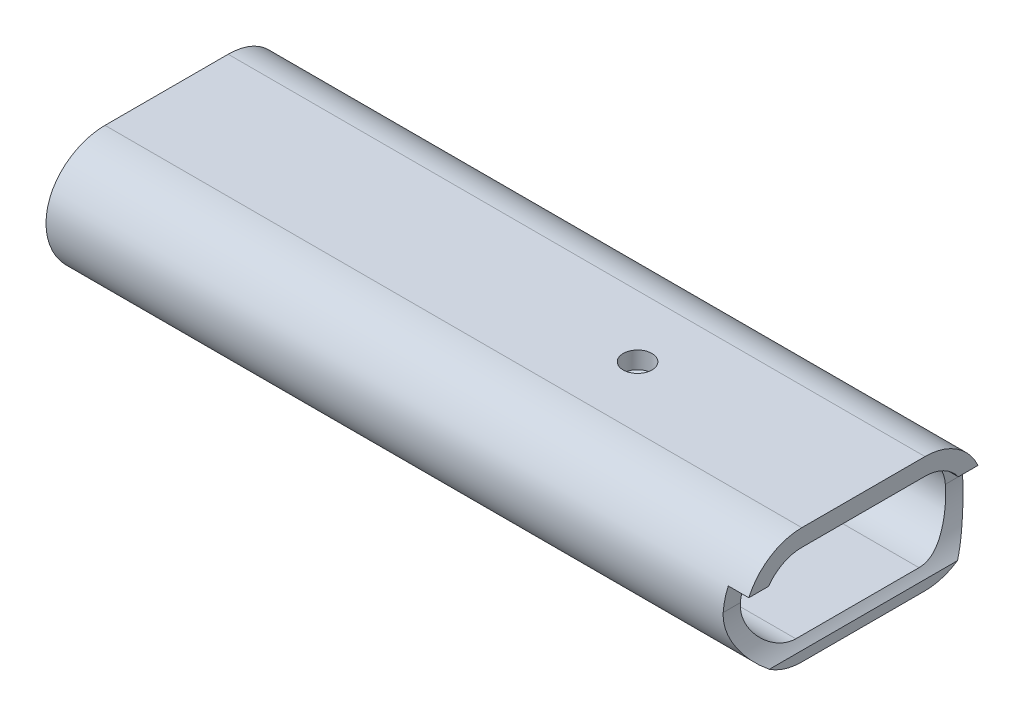
from build123d import *

# Parameters (mm, degrees)
EXTRUSION1_DEPTH             = 51
ENL_V_MAT_EXTRU_2_DEPTH      = 18.5
ENL_V_MAT_EXTRU_2_DEPTH_BACK = 18.5
ENL_V_MAT_EXTRU_3_REACH      = 19
ESQUISSE4_R                  = 2.1
ENL_V_MAT_EXTRU_4_DEPTH      = 18.5000001
ENL_V_MAT_EXTRU_4_DEPTH_BACK = 18.5000001


with BuildPart() as part:
    # Esquisse1 → Extrusion1 (new body, symmetric)
    with BuildSketch(Plane(origin=(0, 0, 0), x_dir=(0, 0, -1), z_dir=(1, 0, 0))):
        with BuildLine():
            Line((-9, -8.5), (9, -8.5))
            ThreePointArc((9, -8.5), (17.5, 0), (9, 8.5))
            Line((9, 8.5), (-9, 8.5))
            ThreePointArc((-9, 8.5), (-17.5, 0), (-9, -8.5))
        make_face()
        with BuildLine():
            Line((-9, 6), (9, 6))
            ThreePointArc((9, 6), (15, 0), (9, -6))
            Line((9, -6), (-9, -6))
            ThreePointArc((-9, -6), (-15, 0), (-9, 6))
        make_face(mode=Mode.SUBTRACT)
    extrude(amount=EXTRUSION1_DEPTH, both=True)

    # Esquisse3 → Enlèv. mat.-Extru.2 (cut, two sides)
    with BuildSketch(Plane.XY) as enl_v_mat_extru_2_sk:
        with BuildLine():
            Line((51, 3.5), (48, 3.5))
            Line((48, 3.5), (48, 0.5))
            ThreePointArc((48, 0.5), (48.77747585, -3.562019202), (51, -7.049834435))
            Line((51, -7.049834435), (51, 3.5))
        make_face()
    extrude(amount=ENL_V_MAT_EXTRU_2_DEPTH, mode=Mode.SUBTRACT)
    extrude(enl_v_mat_extru_2_sk.sketch, amount=-ENL_V_MAT_EXTRU_2_DEPTH_BACK, mode=Mode.SUBTRACT)

    # Esquisse4 → Enlèv. mat.-Extru.3 (cut, up to next)
    with BuildSketch(Plane(origin=(0, 8.5, 0), x_dir=(-1, 0, 0), z_dir=(0, 1, 0)), mode=Mode.PRIVATE) as enl_v_mat_extru_3_sk1:
        with Locations(Location((-18, 0, 0), (0, 0, 90))):  # turned: the seam where the file's is
            Circle(ESQUISSE4_R)
    enl_v_mat_extru_3_tool1 = extrude(enl_v_mat_extru_3_sk1.sketch, amount=-ENL_V_MAT_EXTRU_3_REACH, mode=Mode.PRIVATE) & part.part
    add(enl_v_mat_extru_3_tool1.solids().sort_by_distance((18, 8.5, 0))[0], mode=Mode.SUBTRACT)

    # Esquisse5 → Enlèv. mat.-Extru.4 (cut, two sides)
    with BuildSketch(Plane.XY) as enl_v_mat_extru_4_sk:
        with BuildLine():
            Line((60.682276478, -226.426742354), (-41.324705982, -35.5))
            ThreePointArc((-41.324705982, -35.5), (-49.153043001, -14.164640947), (-50.824705982, 8.5))
            Line((-50.824705982, 8.5), (-36.678065011, 224.505365595))
            Line((-36.678065011, 224.505365595), (-459.862900179, 133.135912547))
            Line((-459.862900179, 133.135912547), (-362.50255869, -317.796195402))
            Line((-362.50255869, -317.796195402), (60.682276478, -226.426742354))
        make_face()
    extrude(amount=ENL_V_MAT_EXTRU_4_DEPTH, mode=Mode.SUBTRACT)
    extrude(enl_v_mat_extru_4_sk.sketch, amount=-ENL_V_MAT_EXTRU_4_DEPTH_BACK, mode=Mode.SUBTRACT)


solid = part.part
